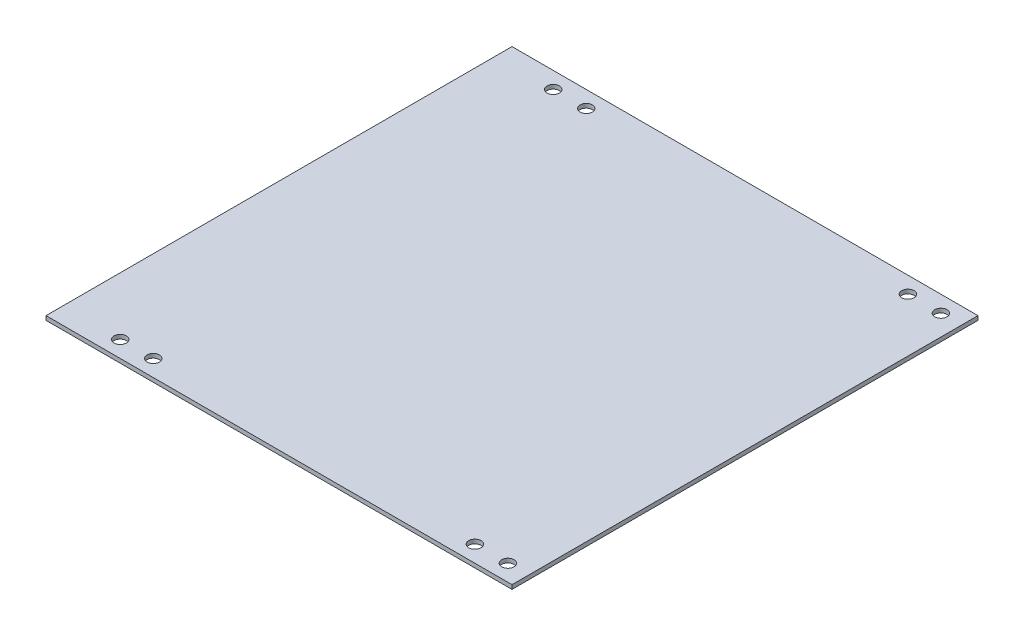
from build123d import *

# Parameters (mm, degrees)
SKETCH1_W           = 358.775
SKETCH1_H           = 358.775
BOSS_EXTRUDE1_DEPTH = 3.175
SKETCH2_R           = 4.7625
CUT_EXTRUDE1_DEPTH  = 4.175


with BuildPart() as part:
    # Sketch1 → Boss-Extrude1 (new body)
    with BuildSketch(Plane(origin=(0, 0, 0), x_dir=(1, 0, 0), z_dir=(0, 1, 0))):
        with Locations((179.3875, 179.3875)):
            Rectangle(SKETCH1_W, SKETCH1_H)
    extrude(amount=BOSS_EXTRUDE1_DEPTH)

    # Sketch2 → Cut-Extrude1 (cut, through all)
    with BuildSketch(Plane(origin=(0, 3.175, 0), x_dir=(1, 0, 0), z_dir=(0, 1, 0))):
        with Locations((44.45, 12.7)):
            Circle(SKETCH2_R)
        with Locations((69.85, 12.7)):
            Circle(SKETCH2_R)
        with Locations((317.5, 12.7)):
            Circle(SKETCH2_R)
        with Locations((342.9, 12.7)):
            Circle(SKETCH2_R)
    cut_extrude1 = extrude(amount=-CUT_EXTRUDE1_DEPTH, mode=Mode.SUBTRACT)

    # Mirror1: Cut-Extrude1 across plane
    add(cut_extrude1.mirror(Plane.XY.offset(-179.3875)), mode=Mode.SUBTRACT)


solid = part.part
